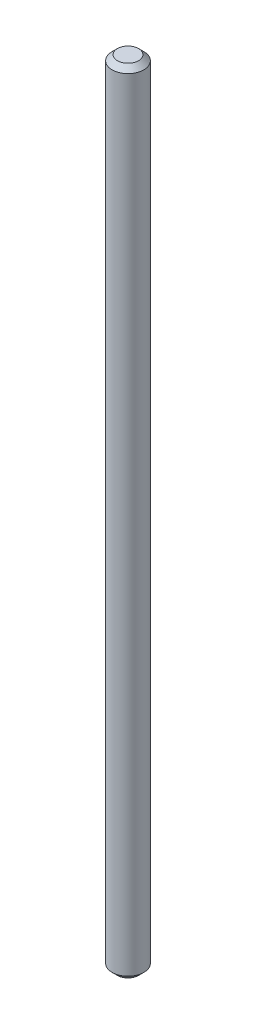
from build123d import *

# Parameters (mm, degrees)
SKETCH1_R           = 9
BOSS_EXTRUDE1_DEPTH = 225
CHAMFER1_SIZE       = 3


with BuildPart() as part:
    # Sketch1 → Boss-Extrude1 (new body, symmetric)
    with BuildSketch(Plane(origin=(0, 0, 0), x_dir=(1, 0, 0), z_dir=(0, 1, 0))):
        Circle(SKETCH1_R)
    extrude(amount=BOSS_EXTRUDE1_DEPTH, both=True)

    # Chamfer1
    chamfer1_edges = [part.edges().sort_by_distance(p)[0] for p in [
        (-9, -225, 0),
        (-9, 225, 0),
    ]]
    chamfer(chamfer1_edges, length=CHAMFER1_SIZE)


solid = part.part
